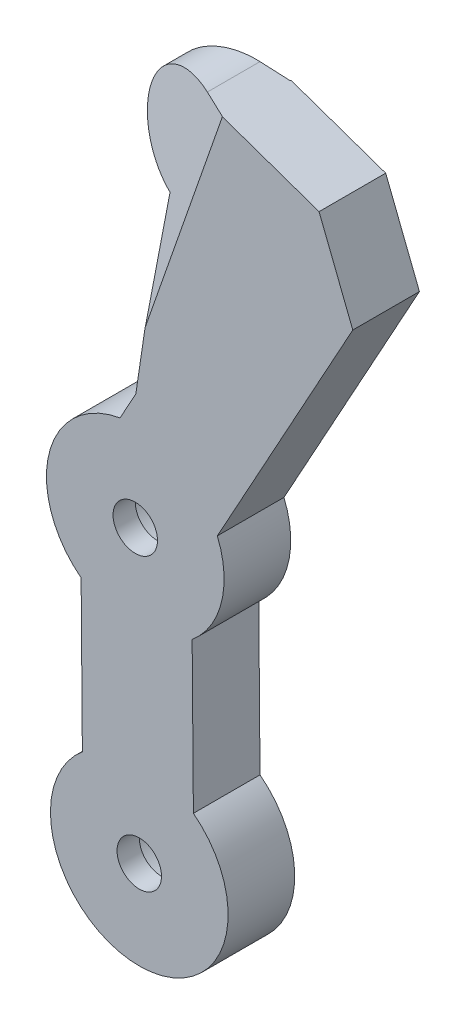
from build123d import *

# Parameters (mm, degrees)
BOSS_EXTRUDE1_DEPTH     = 15
SKETCH2_R               = 11.1
CUT_EXTRUDE1_DEPTH      = 10
SKETCH3_R               = 5
CUT_EXTRUDE2_DEPTH      = 10
CUT_EXTRUDE_THIN7_DEPTH = 62


with BuildPart() as part:
    # Sketch1 → Boss-Extrude1 (new body)
    with BuildSketch(Plane.XY):
        with BuildLine():
            Line((5.505816945, 85.326012217), (5.307768654, 85.393580353))
            ThreePointArc((5.307768654, 85.393580353), (-2.005055015, 101.475976607), (13.940536847, 109.082484312))
            Line((13.940536847, 109.082484312), (40.538740524, 99.7887516))
            Line((40.538740524, 99.7887516), (48.129208704, 80.495248668))
            Line((48.129208704, 80.495248668), (17.636215156, 25.115965593))
            ThreePointArc((17.636215156, 25.115965593), (18.579608232, 12.6739017), (11.964278199, 2.09409296))
            Line((11.964278199, 2.09409296), (12.243619866, -31.678974911))
            ThreePointArc((12.243619866, -31.678974911), (0.468324559, -67.537617109), (-12.751239862, -32.185913949))
            Line((-12.751239862, -32.185913949), (-13.03091257, 1.603476045))
            ThreePointArc((-13.03091257, 1.603476045), (-20.259022529, 22.242640416), (-4.270337109, 37.161843413))
            Line((-4.270337109, 37.161843413), (-0.71558036, 43.617748767))
            Line((-0.71558036, 43.617748767), (5.505816945, 85.326012217))
        make_face()
    extrude(amount=BOSS_EXTRUDE1_DEPTH)

    # Sketch2 → Cut-Extrude1 (cut)
    with BuildSketch(Plane(origin=(0, 0, 0), x_dir=(-1, 0, 0), z_dir=(0, 0, -1))):
        with Locations((0.839707244, 17.458270673)):
            Circle(SKETCH2_R)
        with Locations((-0.062773329, -47.541729327)):
            Circle(SKETCH2_R)
    extrude(amount=-CUT_EXTRUDE1_DEPTH, mode=Mode.SUBTRACT)

    # Sketch3 → Cut-Extrude2 (cut)
    with BuildSketch(Plane(origin=(0, 0, 10), x_dir=(-1, 0, 0), z_dir=(0, 0, -1))):
        with Locations((0.839707244, 17.458270673)):
            Circle(SKETCH3_R)
        with Locations((-0.062773329, -47.541729327)):
            Circle(SKETCH3_R)
    extrude(amount=-CUT_EXTRUDE2_DEPTH, mode=Mode.SUBTRACT)

    # Sketch4 → Cut-Extrude-Thin7 (cut)
    with BuildSketch(Plane(origin=(35.484462303, 101.554777284, 0), x_dir=(0.944031293, -0.329855904, 0), z_dir=(0.329855904, 0.944031293, 0))):
        Polygon((-17.177390776, -0.155952815), (-35.822204189, -5.255346546), (-38.460333018, 4.390392216), (-19.815519606, 9.489785947), align=None)
        Polygon((-36.000883233, -9.902707664), (-17.695137785, -14.971739454), (-20.363805607, -24.609073736), (-38.669551056, -19.540041946), align=None)
    extrude(amount=-CUT_EXTRUDE_THIN7_DEPTH, mode=Mode.SUBTRACT)


solid = part.part
